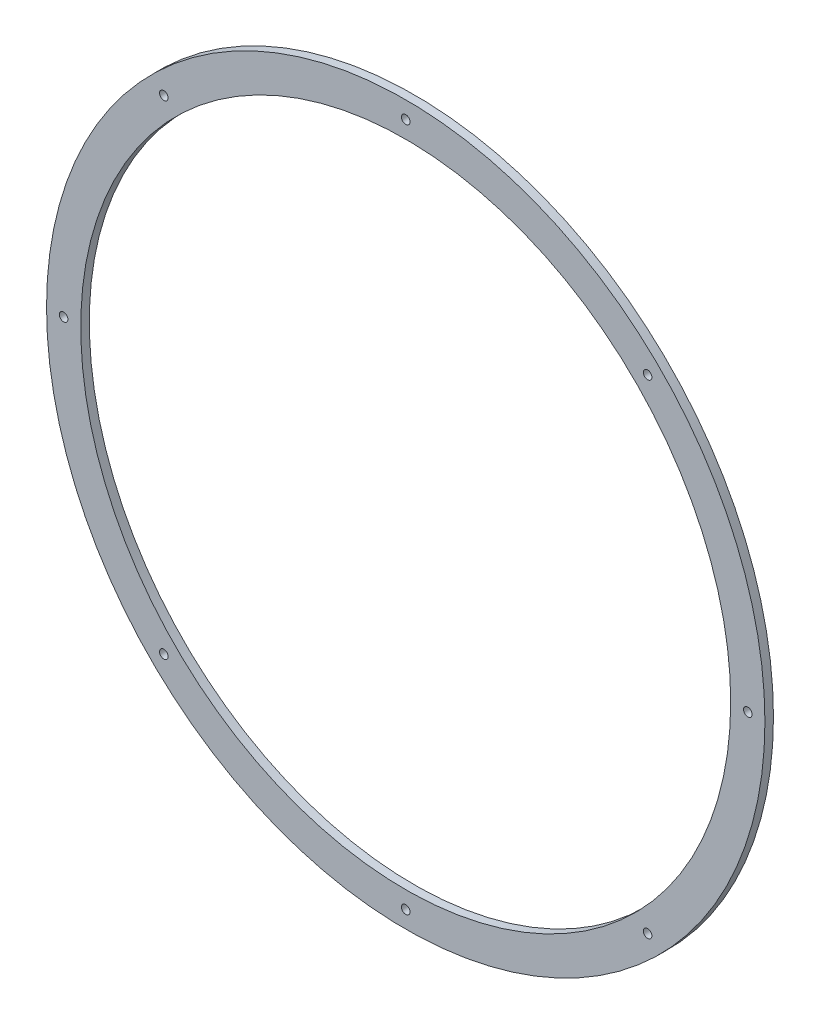
from build123d import *

# Parameters (mm, degrees)
SKETCH1_R           = 210
SKETCH1_R_2         = 190
BOSS_EXTRUDE1_DEPTH = 5
M6_TAPPED_HOLE1_D   = 5
CIRPATTERN1_COUNT   = 8


with BuildPart() as part:
    # Sketch1 → Boss-Extrude1 (new body)
    with BuildSketch(Plane.XY):
        Circle(SKETCH1_R)
        Circle(SKETCH1_R_2, mode=Mode.SUBTRACT)
    extrude(amount=BOSS_EXTRUDE1_DEPTH)

    # M6 Tapped Hole1 (through all)
    with Locations(Plane.XY.offset(5)):
        with Locations((0, 200)):
            m6_tapped_hole1 = Hole(M6_TAPPED_HOLE1_D / 2)

    # CirPattern1: M6 Tapped Hole1 ×8 about axis
    cirpattern1_axis = Axis((0, 0, 0), (0, 0, 1))
    for i in range(1, CIRPATTERN1_COUNT):
        add(m6_tapped_hole1.rotate(cirpattern1_axis, i * 360 / CIRPATTERN1_COUNT), mode=Mode.SUBTRACT)


solid = part.part
